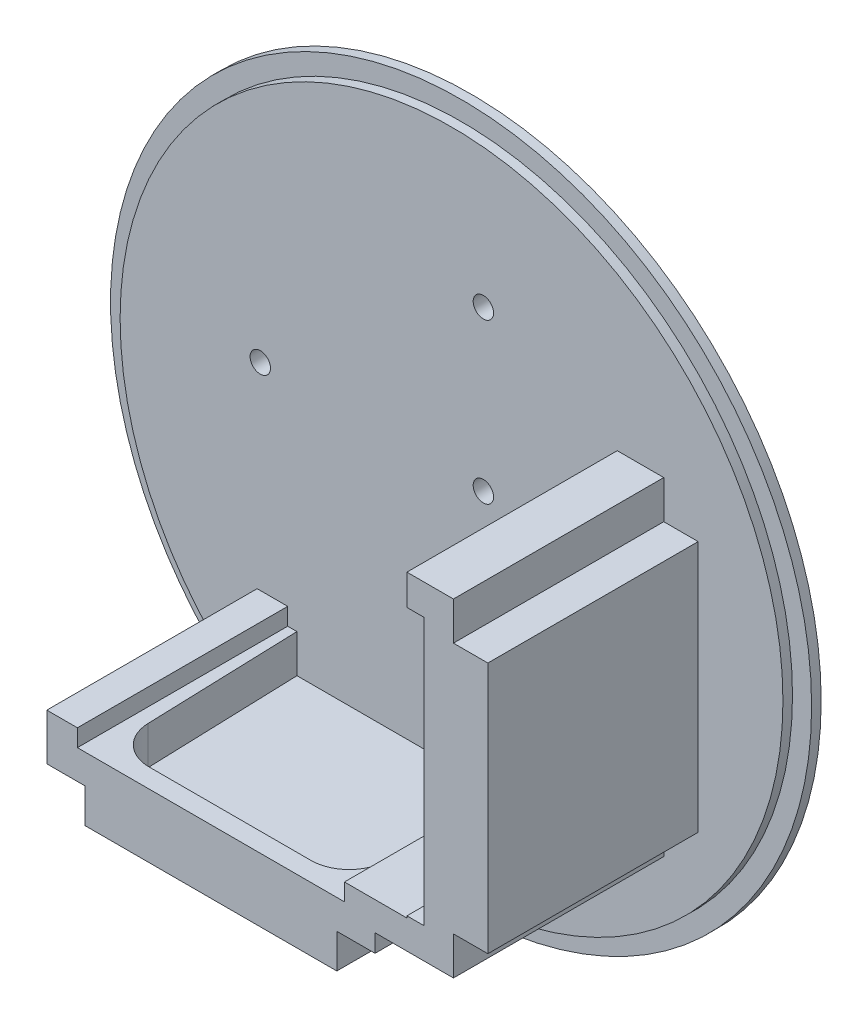
from build123d import *

# Parameters (mm, degrees)
SKIZZE1_R                       = 52
AUFSATZ_LINEAR_AUSTRAGEN1_DEPTH = 3
SKIZZE1_3_R                     = 55
SKIZZE1_3_R_2                   = 52
AUFSATZ_LINEAR_AUSTRAGEN2_DEPTH = 1.5
SCHNITT_LINEAR_AUSTRAGEN1_REACH = 79.84
SKIZZE3_R                       = 1.6
AUFSATZ_LINEAR_AUSTRAGEN3_DEPTH = 33
SCHNITT_LINEAR_AUSTRAGEN4_REACH = 120.458
SCHNITT_LINEAR_START            = -4
VERRUNDUNG1_R                   = 6
SCHNITT_LINEAR_AUSTRAGEN9_DEPTH = 6
VERRUNDUNG2_R                   = 6


with BuildPart() as part:
    # Skizze1 → Aufsatz-Linear austragen1 (new body)
    with BuildSketch(Plane.XY):
        Circle(SKIZZE1_R)
    extrude(amount=AUFSATZ_LINEAR_AUSTRAGEN1_DEPTH)

    # Skizze1_3 → Aufsatz-Linear austragen2 (add)
    with BuildSketch(Plane.XY):
        Circle(SKIZZE1_3_R)
        Circle(SKIZZE1_3_R_2, mode=Mode.SUBTRACT)
    extrude(amount=AUFSATZ_LINEAR_AUSTRAGEN2_DEPTH)

    # Skizze3 → Schnitt-Linear austragen1 (cut, up to next)
    with BuildSketch(Plane.XY.offset(3), mode=Mode.PRIVATE) as schnitt_linear_austragen1_sk1:
        with Locations((4.995000167, 4.995918163)):
            Circle(SKIZZE3_R)
    schnitt_linear_austragen1_tool1 = extrude(schnitt_linear_austragen1_sk1.sketch, amount=-SCHNITT_LINEAR_AUSTRAGEN1_REACH, mode=Mode.PRIVATE) & part.part
    # Skizze3 → Schnitt-Linear austragen1 (cut, up to next)
    with BuildSketch(Plane.XY.offset(3), mode=Mode.PRIVATE) as schnitt_linear_austragen1_sk2:
        with Locations((4.995000167, 29.995918163)):
            Circle(SKIZZE3_R)
    schnitt_linear_austragen1_tool2 = extrude(schnitt_linear_austragen1_sk2.sketch, amount=-SCHNITT_LINEAR_AUSTRAGEN1_REACH, mode=Mode.PRIVATE) & part.part
    # Skizze3 → Schnitt-Linear austragen1 (cut, up to next)
    with BuildSketch(Plane.XY.offset(3), mode=Mode.PRIVATE) as schnitt_linear_austragen1_sk3:
        with Locations((-30.004999833, 4.995918163)):
            Circle(SKIZZE3_R)
    schnitt_linear_austragen1_tool3 = extrude(schnitt_linear_austragen1_sk3.sketch, amount=-SCHNITT_LINEAR_AUSTRAGEN1_REACH, mode=Mode.PRIVATE) & part.part
    add(schnitt_linear_austragen1_tool1.solids().sort_by_distance((4.995, 4.995918, 3))[0], mode=Mode.SUBTRACT)
    add(schnitt_linear_austragen1_tool2.solids().sort_by_distance((4.995, 29.995918, 3))[0], mode=Mode.SUBTRACT)
    add(schnitt_linear_austragen1_tool3.solids().sort_by_distance((-30.005, 4.995918, 3))[0], mode=Mode.SUBTRACT)

    # Skizze2 → Aufsatz-Linear austragen3 (add)
    with BuildSketch(Plane.XY.offset(3)):
        Polygon((26, 21), (26, 16.2), (27.2, 16.2), (28.7, 16.2), (28.7, 15), (28.7, -24.5), (28.7, -25.7), (27.2, -25.7), (26, -25.7), (26, -26), (21, -26), (16.2, -26), (16.2, -27.2), (16.2, -28.7), (15, -28.7), (-24.5, -28.7), (-25.7, -28.7), (-25.7, -27.2), (-25.7, -26), (-30.5, -26), (-30.5, -33.3), (-24.5, -33.3), (-24.5, -38.7), (15, -38.7), (15, -33.3), (21, -33.3), (21, -30.5), (26, -30.5), (33.3, -30.5), (33.3, -24.5), (38.7, -24.5), (38.7, 15), (33.3, 15), (33.3, 21), align=None)
    extrude(amount=AUFSATZ_LINEAR_AUSTRAGEN3_DEPTH)

    # Skizze6 → Schnitt-Linear austragen4 (cut, up to next)
    with BuildSketch(Plane.XZ.offset(38.7).offset(SCHNITT_LINEAR_START), mode=Mode.PRIVATE) as schnitt_linear_austragen4_sk1:
        Polygon((-24.25, 3), (-23.25, 33), (13.75, 33), (14.75, 3), align=None)
    schnitt_linear_austragen4_tool1 = extrude(schnitt_linear_austragen4_sk1.sketch, amount=-SCHNITT_LINEAR_AUSTRAGEN4_REACH, mode=Mode.PRIVATE) & part.part
    add(schnitt_linear_austragen4_tool1.solids().sort_by_distance((-4.75, -34.7, 17.868421))[0], mode=Mode.SUBTRACT)

    # Verrundung1
    verrundung1_edges = [part.edges().sort_by_distance(p)[0] for p in [
        (-23.25, -31.7, 33),
        (13.75, -31.7, 33),
    ]]
    fillet(verrundung1_edges, radius=VERRUNDUNG1_R)

    # Skizze7 → Schnitt-Linear austragen9 (cut)
    with BuildSketch(Plane.ZY.offset(-28.7)):
        Polygon((33, -23.25), (33, 13.75), (3, 14.75), (3, -24.25), align=None)
    extrude(amount=-SCHNITT_LINEAR_AUSTRAGEN9_DEPTH, mode=Mode.SUBTRACT)

    # Verrundung2
    verrundung2_edges = [part.edges().sort_by_distance(p)[0] for p in [
        (31.7, -23.25, 33),
        (31.7, 13.75, 33),
    ]]
    fillet(verrundung2_edges, radius=VERRUNDUNG2_R)


solid = part.part
